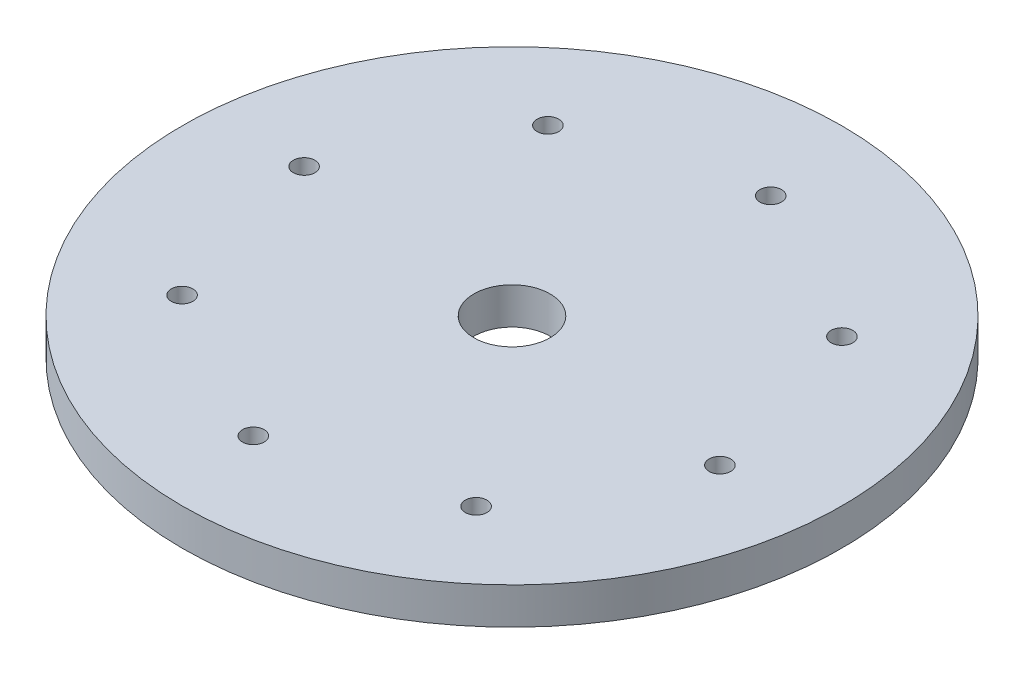
from build123d import *

# Parameters (mm, degrees)
SKETCH1_R           = 53.5432
SKETCH1_R_2         = 6.1849
SKETCH1_R_3         = 1.75895
BOSS_EXTRUDE1_DEPTH = 5.9563


with BuildPart() as part:
    # Sketch1 → Boss-Extrude1 (new body)
    with BuildSketch(Plane(origin=(0, 0, 0), x_dir=(1, 0, 0), z_dir=(0, 1, 0))):
        Circle(SKETCH1_R)
        Circle(SKETCH1_R_2, mode=Mode.SUBTRACT)
        with Locations((37.90315, -4.125319175)):
            Circle(SKETCH1_R_3, mode=Mode.SUBTRACT)
        with Locations((23.88453323, -29.718615557)):
            Circle(SKETCH1_R_3, mode=Mode.SUBTRACT)
        with Locations((-4.125319175, -37.90315)):
            Circle(SKETCH1_R_3, mode=Mode.SUBTRACT)
        with Locations((-29.718615557, -23.88453323)):
            Circle(SKETCH1_R_3, mode=Mode.SUBTRACT)
        with Locations((-37.90315, 4.125319175)):
            Circle(SKETCH1_R_3, mode=Mode.SUBTRACT)
        with Locations((-23.88453323, 29.718615557)):
            Circle(SKETCH1_R_3, mode=Mode.SUBTRACT)
        with Locations((4.125319175, 37.90315)):
            Circle(SKETCH1_R_3, mode=Mode.SUBTRACT)
        with Locations((29.718615557, 23.88453323)):
            Circle(SKETCH1_R_3, mode=Mode.SUBTRACT)
    extrude(amount=BOSS_EXTRUDE1_DEPTH)


solid = part.part
